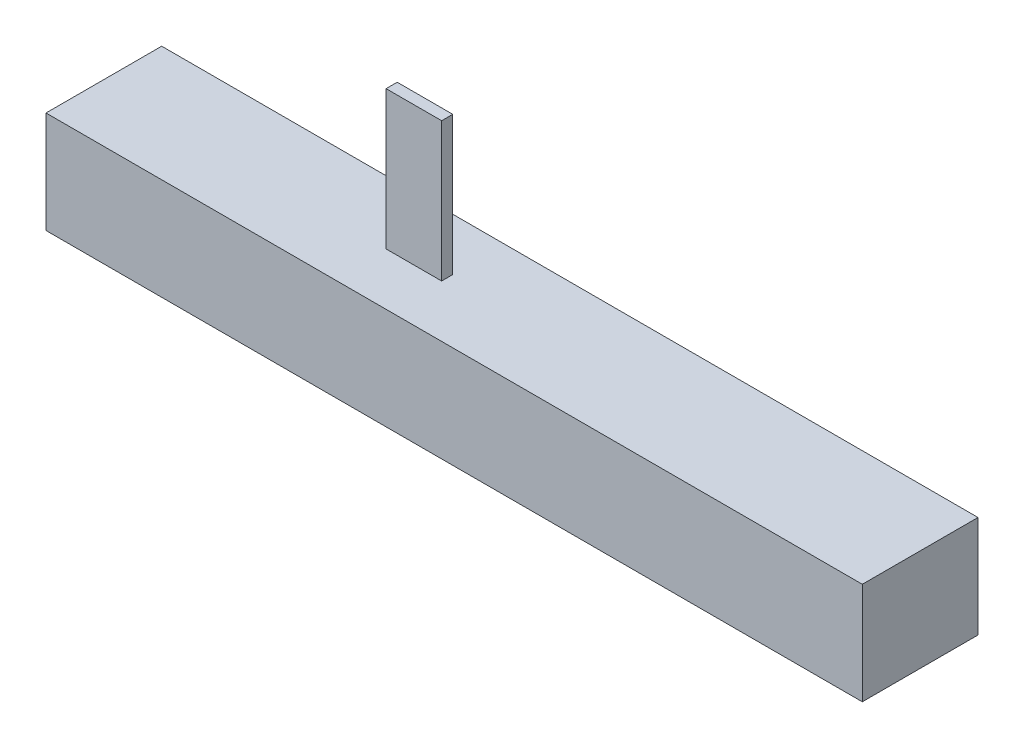
from build123d import *

# Parameters (mm, degrees)
SKETCH1_W           = 88.2
SKETCH1_H           = 11
BOSS_EXTRUDE1_DEPTH = 12.5
SKETCH2_W           = 6
SKETCH2_H           = 1.2
BOSS_EXTRUDE2_DEPTH = 15


with BuildPart() as part:
    # Sketch1 → Boss-Extrude1 (new body)
    with BuildSketch(Plane.XY):
        Rectangle(SKETCH1_W, SKETCH1_H)
    extrude(amount=BOSS_EXTRUDE1_DEPTH)

    # Sketch2 → Boss-Extrude2 (add)
    with BuildSketch(Plane(origin=(0, 5.5, 0), x_dir=(1, 0, 0), z_dir=(0, 1, 0))):
        with Locations((-10.002627366, -6.25)):
            Rectangle(SKETCH2_W, SKETCH2_H)
    extrude(amount=BOSS_EXTRUDE2_DEPTH)


solid = part.part
